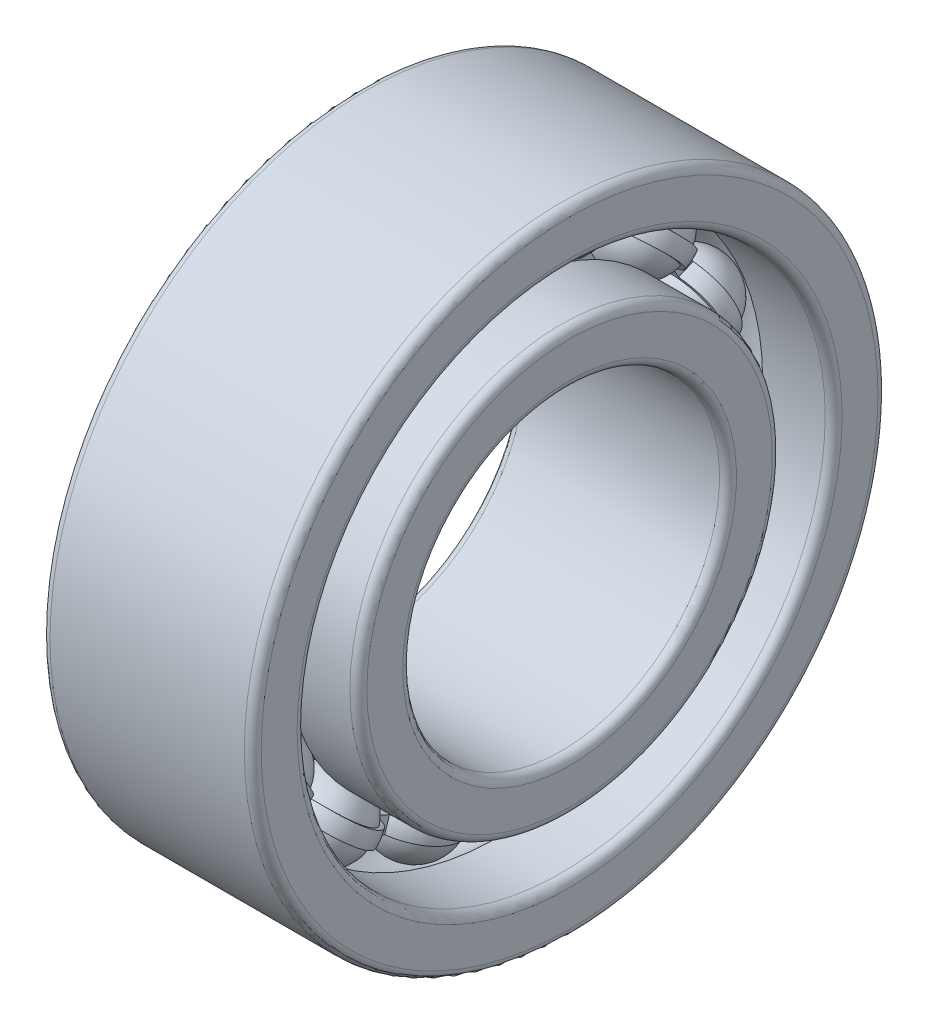
from build123d import *
from build123d.topology import SkipClean

# Parameters (mm, degrees)
SKETCH_5_W               = 0.22499999999999995
SKETCH_5_H               = 0.1500000000000008
PATTERN_CIRCULAR_5_COUNT = 15
PATTERN_CIRCULAR_2_COUNT = 15


with BuildPart() as part:
    # 草图2 → 旋转1 (revolve)
    with BuildSketch(Plane.XY):
        with BuildLine():
            Line((0.9200000000000028, 1.4999999999999996), (-0.9199999999999976, 1.4999999999999996))
            ThreePointArc((-0.9199999999999976, 1.4999999999999996), (-0.9765685424949219, 1.5234314575050756), (-0.9999999999999983, 1.5799999999999998))
            Line((-0.9999999999999983, 1.5799999999999998), (-0.9999999999999983, 1.9199999999999982))
            ThreePointArc((-0.9999999999999983, 1.9199999999999982), (-0.9765685424949219, 1.976568542494922), (-0.919999999999998, 1.9999999999999982))
            Line((-0.919999999999998, 1.9999999999999982), (-0.27950849718746645, 1.9999999999999982))
            ThreePointArc((-0.27950849718746645, 1.9999999999999982), (1.29e-15, 1.8750000000000018), (0.27950849718746645, 1.9999999999999982))
            Line((0.27950849718746645, 1.9999999999999982), (0.9200000000000033, 1.9999999999999982))
            ThreePointArc((0.9200000000000033, 1.9999999999999982), (0.9765685424949273, 1.9765685424949222), (1.0000000000000036, 1.9199999999999982))
            Line((1.0000000000000036, 1.9199999999999982), (1.0000000000000036, 1.5799999999999998))
            ThreePointArc((1.0000000000000036, 1.5799999999999998), (0.9765685424949271, 1.5234314575050756), (0.9200000000000028, 1.4999999999999996))
        make_face()
        with BuildLine():
            Line((-0.9999999999999974, 2.919999999999999), (-0.9999999999999974, 2.579999999999999))
            ThreePointArc((-0.9999999999999974, 2.579999999999999), (-0.9765685424949213, 2.5234314575050756), (-0.9199999999999976, 2.4999999999999987))
            Line((-0.9199999999999976, 2.4999999999999987), (-0.2795084971874695, 2.4999999999999987))
            ThreePointArc((-0.2795084971874695, 2.4999999999999987), (1.29e-15, 2.6249999999999933), (0.2795084971874695, 2.4999999999999987))
            Line((0.2795084971874695, 2.4999999999999987), (0.9200000000000033, 2.4999999999999987))
            ThreePointArc((0.9200000000000033, 2.4999999999999987), (0.9765685424949274, 2.523431457505075), (1.0000000000000036, 2.579999999999999))
            Line((1.0000000000000036, 2.579999999999999), (1.000000000000003, 2.919999999999999))
            ThreePointArc((1.000000000000003, 2.919999999999999), (0.9765685424949269, 2.976568542494923), (0.9200000000000028, 2.999999999999999))
            Line((0.9200000000000028, 2.999999999999999), (-0.9199999999999973, 2.999999999999999))
            ThreePointArc((-0.9199999999999973, 2.999999999999999), (-0.9765685424949211, 2.976568542494923), (-0.9999999999999974, 2.919999999999999))
        make_face()
    revolve(axis=Axis((-3.4999999999999996, 0, 0), (1, 0, 0)))


with BuildPart() as body_2:
    # 草图5 → 旋转3 (revolve)
    with BuildSketch(Plane.XY):
        with Locations((2.33e-15, 2.2500000000000018)):
            Rectangle(SKETCH_5_W, SKETCH_5_H)
    revolve(axis=Axis((-19.927092192426834, 0, 0), (1, 0, 0)))



with BuildPart() as body_3:
    # 草图3 → 旋转2 (revolve)
    with BuildSketch(Plane.XY):
        with BuildLine():
            ThreePointArc((0.4124999999999963, 2.2500000000000004), (0, 2.6624999999999934), (-0.4124999999999963, 2.2500000000000004))
            Line((-0.4124999999999964, 2.2500000000000004), (0.4124999999999964, 2.2500000000000004))
        make_face()
    revolve(axis=Axis((-0.4124999999999964, 2.2500000000000004, 0), (1, 0, 0)))


with BuildPart() as pattern_circular_5_1:
    # 阵列(圆周)5: pattern copy
    add(body_3.part.rotate(Axis((-3.850000000000002, 0, 0), (1, 0, 0)), 1 * 360 / PATTERN_CIRCULAR_5_COUNT))


with BuildPart() as pattern_circular_5_2:
    # 阵列(圆周)5: pattern copy
    add(body_3.part.rotate(Axis((-3.850000000000002, 0, 0), (1, 0, 0)), 2 * 360 / PATTERN_CIRCULAR_5_COUNT))


with BuildPart() as pattern_circular_5_3:
    # 阵列(圆周)5: pattern copy
    add(body_3.part.rotate(Axis((-3.850000000000002, 0, 0), (1, 0, 0)), 3 * 360 / PATTERN_CIRCULAR_5_COUNT))


with BuildPart() as pattern_circular_5_4:
    # 阵列(圆周)5: pattern copy
    add(body_3.part.rotate(Axis((-3.850000000000002, 0, 0), (1, 0, 0)), 4 * 360 / PATTERN_CIRCULAR_5_COUNT))


with BuildPart() as pattern_circular_5_5:
    # 阵列(圆周)5: pattern copy
    add(body_3.part.rotate(Axis((-3.850000000000002, 0, 0), (1, 0, 0)), 5 * 360 / PATTERN_CIRCULAR_5_COUNT))


with BuildPart() as pattern_circular_5_6:
    # 阵列(圆周)5: pattern copy
    add(body_3.part.rotate(Axis((-3.850000000000002, 0, 0), (1, 0, 0)), 6 * 360 / PATTERN_CIRCULAR_5_COUNT))


with BuildPart() as pattern_circular_5_7:
    # 阵列(圆周)5: pattern copy
    add(body_3.part.rotate(Axis((-3.850000000000002, 0, 0), (1, 0, 0)), 7 * 360 / PATTERN_CIRCULAR_5_COUNT))


with BuildPart() as pattern_circular_5_8:
    # 阵列(圆周)5: pattern copy
    add(body_3.part.rotate(Axis((-3.850000000000002, 0, 0), (1, 0, 0)), 8 * 360 / PATTERN_CIRCULAR_5_COUNT))


with BuildPart() as pattern_circular_5_9:
    # 阵列(圆周)5: pattern copy
    add(body_3.part.rotate(Axis((-3.850000000000002, 0, 0), (1, 0, 0)), 9 * 360 / PATTERN_CIRCULAR_5_COUNT))


with BuildPart() as pattern_circular_5_10:
    # 阵列(圆周)5: pattern copy
    add(body_3.part.rotate(Axis((-3.850000000000002, 0, 0), (1, 0, 0)), 10 * 360 / PATTERN_CIRCULAR_5_COUNT))


with BuildPart() as pattern_circular_5_11:
    # 阵列(圆周)5: pattern copy
    add(body_3.part.rotate(Axis((-3.850000000000002, 0, 0), (1, 0, 0)), 11 * 360 / PATTERN_CIRCULAR_5_COUNT))


with BuildPart() as pattern_circular_5_12:
    # 阵列(圆周)5: pattern copy
    add(body_3.part.rotate(Axis((-3.850000000000002, 0, 0), (1, 0, 0)), 12 * 360 / PATTERN_CIRCULAR_5_COUNT))


with BuildPart() as pattern_circular_5_13:
    # 阵列(圆周)5: pattern copy
    add(body_3.part.rotate(Axis((-3.850000000000002, 0, 0), (1, 0, 0)), 13 * 360 / PATTERN_CIRCULAR_5_COUNT))


with BuildPart() as pattern_circular_5_14:
    # 阵列(圆周)5: pattern copy
    add(body_3.part.rotate(Axis((-3.850000000000002, 0, 0), (1, 0, 0)), 14 * 360 / PATTERN_CIRCULAR_5_COUNT))


with BuildPart() as cut_revolve_1_tool:
    # 草图6 → 切除-旋转1 (revolve)
    with BuildSketch(Plane.XY):
        with BuildLine():
            Line((-0.4056245184896952, 2.3250000000000006), (0.4056245184896952, 2.3250000000000006))
            ThreePointArc((0.4056245184896952, 2.3250000000000006), (2.98e-15, 2.6624999999999934), (-0.4056245184896952, 2.3250000000000006))
        make_face()
        with BuildLine():
            Line((-0.4056245184896952, 2.175), (0.4056245184896952, 2.175))
            ThreePointArc((0.4056245184896952, 2.175), (3.07e-15, 1.8375000000000004), (-0.4056245184896952, 2.175))
        make_face()
    revolve(axis=Axis((-19.927092192426834, 0, 0), (1, 0, 0)))


with BuildPart() as part_1:
    add(part.part)

    # 切除-旋转1: cut by cut_revolve_1_tool
    add(cut_revolve_1_tool.part, mode=Mode.SUBTRACT)


with BuildPart() as body_3_1:
    add(body_3.part)

    # 切除-旋转1: cut by cut_revolve_1_tool
    add(cut_revolve_1_tool.part, mode=Mode.SUBTRACT)


with BuildPart() as pattern_circular_5_1_1:
    add(pattern_circular_5_1.part)

    # 切除-旋转1: cut by cut_revolve_1_tool
    add(cut_revolve_1_tool.part, mode=Mode.SUBTRACT)


with BuildPart() as pattern_circular_5_2_1:
    add(pattern_circular_5_2.part)

    # 切除-旋转1: cut by cut_revolve_1_tool
    add(cut_revolve_1_tool.part, mode=Mode.SUBTRACT)


with BuildPart() as pattern_circular_5_3_1:
    add(pattern_circular_5_3.part)

    # 切除-旋转1: cut by cut_revolve_1_tool
    add(cut_revolve_1_tool.part, mode=Mode.SUBTRACT)


with BuildPart() as pattern_circular_5_4_1:
    add(pattern_circular_5_4.part)

    # 切除-旋转1: cut by cut_revolve_1_tool
    add(cut_revolve_1_tool.part, mode=Mode.SUBTRACT)


with BuildPart() as pattern_circular_5_5_1:
    add(pattern_circular_5_5.part)

    # 切除-旋转1: cut by cut_revolve_1_tool
    add(cut_revolve_1_tool.part, mode=Mode.SUBTRACT)


with BuildPart() as pattern_circular_5_6_1:
    add(pattern_circular_5_6.part)

    # 切除-旋转1: cut by cut_revolve_1_tool
    add(cut_revolve_1_tool.part, mode=Mode.SUBTRACT)


with BuildPart() as pattern_circular_5_7_1:
    add(pattern_circular_5_7.part)

    # 切除-旋转1: cut by cut_revolve_1_tool
    add(cut_revolve_1_tool.part, mode=Mode.SUBTRACT)


with BuildPart() as pattern_circular_5_8_1:
    add(pattern_circular_5_8.part)

    # 切除-旋转1: cut by cut_revolve_1_tool
    add(cut_revolve_1_tool.part, mode=Mode.SUBTRACT)


with BuildPart() as pattern_circular_5_9_1:
    add(pattern_circular_5_9.part)

    # 切除-旋转1: cut by cut_revolve_1_tool
    add(cut_revolve_1_tool.part, mode=Mode.SUBTRACT)


with BuildPart() as pattern_circular_5_10_1:
    add(pattern_circular_5_10.part)

    # 切除-旋转1: cut by cut_revolve_1_tool
    add(cut_revolve_1_tool.part, mode=Mode.SUBTRACT)


with BuildPart() as pattern_circular_5_11_1:
    add(pattern_circular_5_11.part)

    # 切除-旋转1: cut by cut_revolve_1_tool
    add(cut_revolve_1_tool.part, mode=Mode.SUBTRACT)


with BuildPart() as pattern_circular_5_12_1:
    add(pattern_circular_5_12.part)

    # 切除-旋转1: cut by cut_revolve_1_tool
    add(cut_revolve_1_tool.part, mode=Mode.SUBTRACT)


with BuildPart() as pattern_circular_5_13_1:
    add(pattern_circular_5_13.part)

    # 切除-旋转1: cut by cut_revolve_1_tool
    add(cut_revolve_1_tool.part, mode=Mode.SUBTRACT)


with BuildPart() as pattern_circular_5_14_1:
    add(pattern_circular_5_14.part)

    # 切除-旋转1: cut by cut_revolve_1_tool
    add(cut_revolve_1_tool.part, mode=Mode.SUBTRACT)


with BuildPart() as body_2_1:
    with SkipClean():  # the faces are left unmerged after this step: merging them gives an invalid solid
        add(body_2.part)

        add(body_3_1.part)  # 旋转4 merges body 3
        # 草图7 → 旋转4 (revolve)
        with BuildSketch(Plane.XY):
            with BuildLine():
                Line((-0.3749999999999949, 2.2500000000000004), (0.3749999999999949, 2.2500000000000004))
                ThreePointArc((0.3749999999999949, 2.2500000000000004), (3.71e-15, 2.6249999999999916), (-0.3749999999999949, 2.2500000000000004))
            make_face()
        revolve_4 = revolve(axis=Axis((-0.3749999999999949, 2.2500000000000004, 0), (1, 0, 0)))

    # 阵列(圆周)2: 旋转4 ×15 about axis
    with SkipClean():  # the faces are left unmerged after this step: merging them gives an invalid solid
        pattern_circular_2_axis = Axis((-3.850000000000002, 0, 0), (1, 0, 0))
        for i in range(1, PATTERN_CIRCULAR_2_COUNT):
            add(revolve_4.rotate(pattern_circular_2_axis, i * 360 / PATTERN_CIRCULAR_2_COUNT))


solid = Compound([part_1.part, pattern_circular_5_1_1.part, pattern_circular_5_2_1.part, pattern_circular_5_3_1.part, pattern_circular_5_4_1.part, pattern_circular_5_5_1.part, pattern_circular_5_6_1.part, pattern_circular_5_7_1.part, pattern_circular_5_8_1.part, pattern_circular_5_9_1.part, pattern_circular_5_10_1.part, pattern_circular_5_11_1.part, pattern_circular_5_12_1.part, pattern_circular_5_13_1.part, pattern_circular_5_14_1.part, body_2_1.part])
